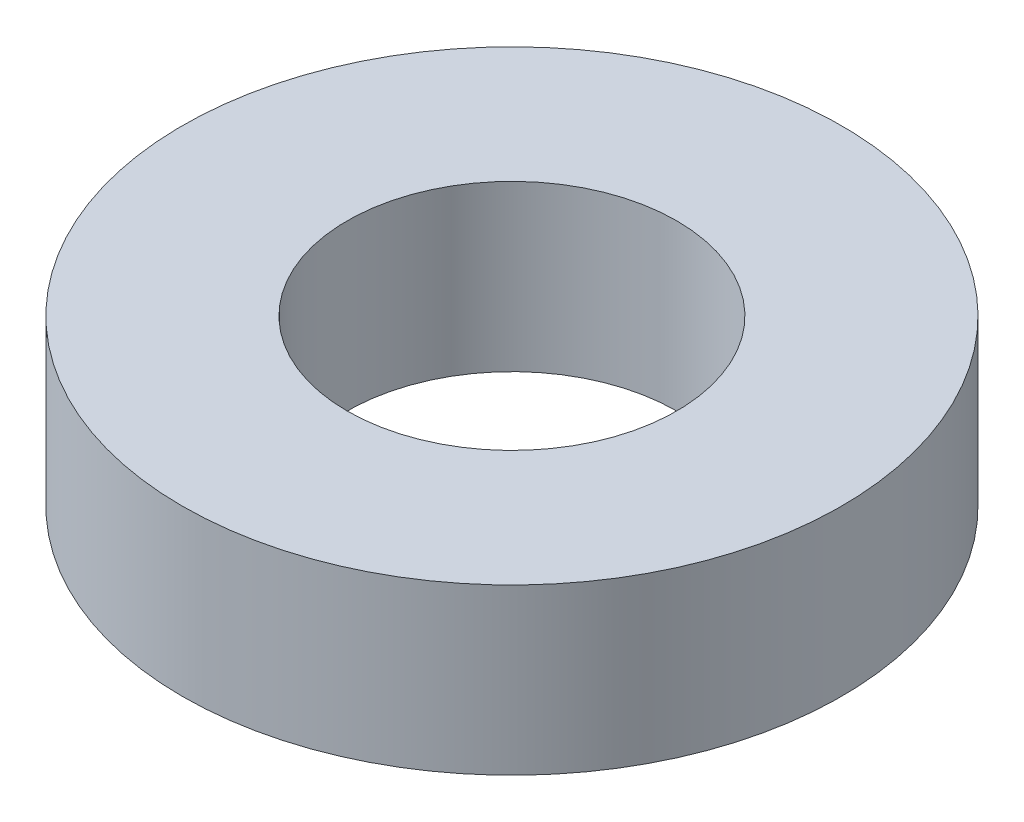
from build123d import *

# Parameters (mm, degrees)
SKETCH_1_R      = 40
SKETCH_1_R_2    = 20
EXTRUDE_1_DEPTH = 20


with BuildPart() as part:
    # 草图1 → 凸台-拉伸1 (new body)
    with BuildSketch(Plane(origin=(0, 0, 0), x_dir=(1, 0, 0), z_dir=(0, 1, 0))):
        Circle(SKETCH_1_R)
        Circle(SKETCH_1_R_2, mode=Mode.SUBTRACT)
    extrude(amount=EXTRUDE_1_DEPTH)


solid = part.part
